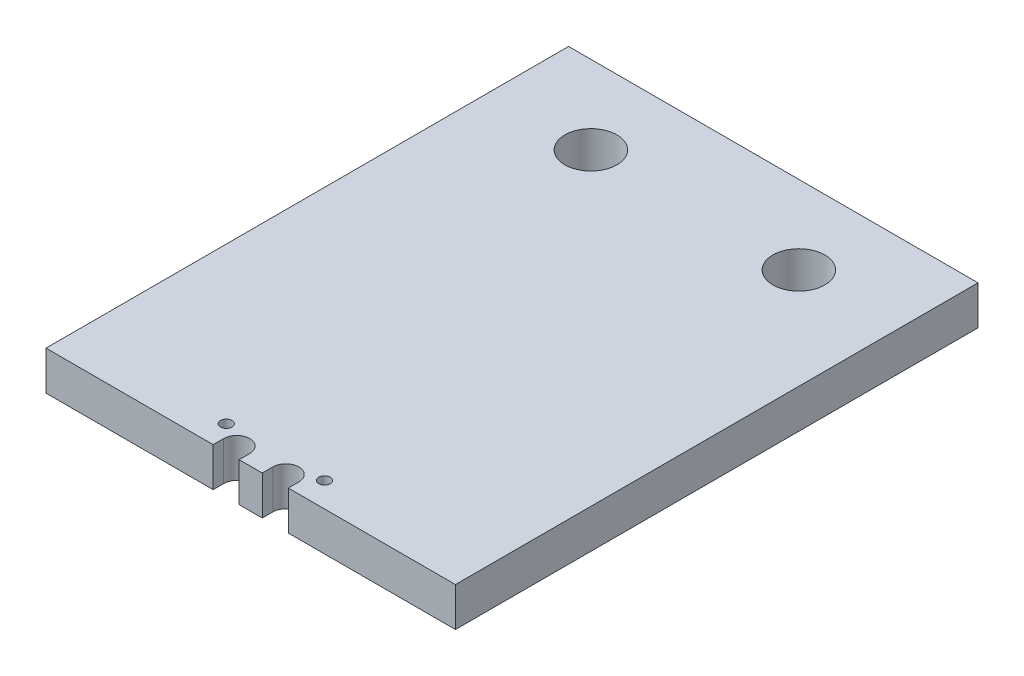
from build123d import *

# Parameters (mm, degrees)
SKETCH1_R           = 0.7
SKETCH1_R_2         = 3.175
BOSS_EXTRUDE1_DEPTH = 4.7625


with BuildPart() as part:
    # Sketch1 → Boss-Extrude1 (new body)
    with BuildSketch(Plane(origin=(0, 0, 0), x_dir=(1, 0, 0), z_dir=(0, 1, 0))):
        with BuildLine():
            Line((16, 1.185131266), (36.4125, 1.185131266))
            Line((36.4125, 1.185131266), (36.4125, 2.47623548))
            ThreePointArc((36.4125, 2.47623548), (38, 4.06373548), (39.5875, 2.47623548))
            Line((39.5875, 2.47623548), (39.5875, 1.185131266))
            Line((39.5875, 1.185131266), (42.4125, 1.185131266))
            Line((42.4125, 1.185131266), (42.4125, 2.47623548))
            ThreePointArc((42.4125, 2.47623548), (44, 4.06373548), (45.5875, 2.47623548))
            Line((45.5875, 2.47623548), (45.5875, 1.185131266))
            Line((45.5875, 1.185131266), (66, 1.185131266))
            Line((66, 1.185131266), (66, 65))
            Line((66, 65), (16, 65))
            Line((16, 65), (16, 1.185131266))
        make_face()
        with Locations((35, 4.197327459)):
            Circle(SKETCH1_R, mode=Mode.SUBTRACT)
        with Locations((53.7, 55.426122104)):
            Circle(SKETCH1_R_2, mode=Mode.SUBTRACT)
        with Locations((28.3, 55.426122104)):
            Circle(SKETCH1_R_2, mode=Mode.SUBTRACT)
        with Locations((47, 4.197327459)):
            Circle(SKETCH1_R, mode=Mode.SUBTRACT)
    extrude(amount=-BOSS_EXTRUDE1_DEPTH)


solid = part.part
